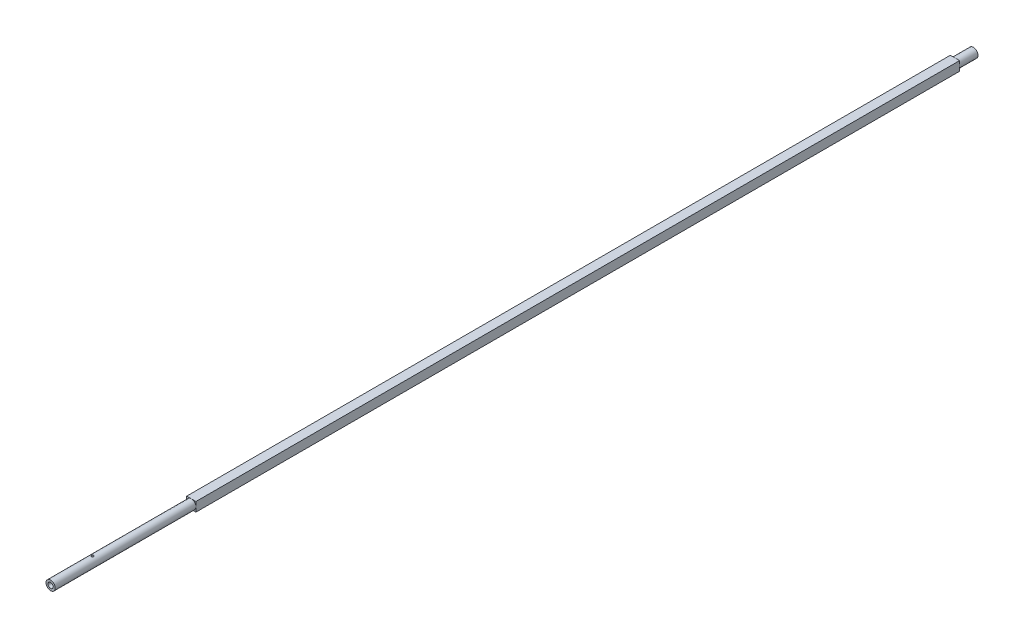
from build123d import *

# Parameters (mm, degrees)
BOSS_EXTRUDE2_DEPTH      = 3.16
BOSS_EXTRUDE2_DEPTH_BACK = 3.16
SKETCH5_W                = 6.32
SKETCH5_H                = 521.14
CUT_EXTRUDE1_DEPTH       = 534.718709809
CUT_EXTRUDE1_DEPTH_BACK  = 534.718709809
SKETCH4_R                = 0.775


with BuildPart() as part:
    # Sketch1 → Revolve1 (revolve)
    with BuildSketch(Plane(origin=(0, 0, 0), x_dir=(0, 0, -1), z_dir=(1, 0, 0))):
        Polygon((533.7, 1.805), (528.7, 0), (-91.02, 0), (-96.02, 1.805), (-96.02, 3.155), (533.7, 3.155), align=None)
    revolve(axis=Axis((0, 0, 0), (0, 0, 1)))

    # Sketch5 → Boss-Extrude2 (add, two sides: drawn at the far end of the back side and taken through both)
    with BuildSketch(Plane(origin=(0, 0, 0), x_dir=(1, 0, 0), z_dir=(0, 1, 0)).offset(-BOSS_EXTRUDE2_DEPTH_BACK)):
        with Locations((0, 260.57)):
            Rectangle(SKETCH5_W, SKETCH5_H)
    extrude(amount=BOSS_EXTRUDE2_DEPTH + BOSS_EXTRUDE2_DEPTH_BACK)

    # Sketch4 → Cut-Extrude1 (cut, two sides: drawn at the far end of the back side and taken through both)
    with BuildSketch(Plane(origin=(0, 0, 0), x_dir=(1, 0, 0), z_dir=(0, 1, 0)).offset(-CUT_EXTRUDE1_DEPTH_BACK)):
        with Locations((0, -67.495)):
            Circle(SKETCH4_R)
    extrude(amount=CUT_EXTRUDE1_DEPTH + CUT_EXTRUDE1_DEPTH_BACK, mode=Mode.SUBTRACT)


solid = part.part
